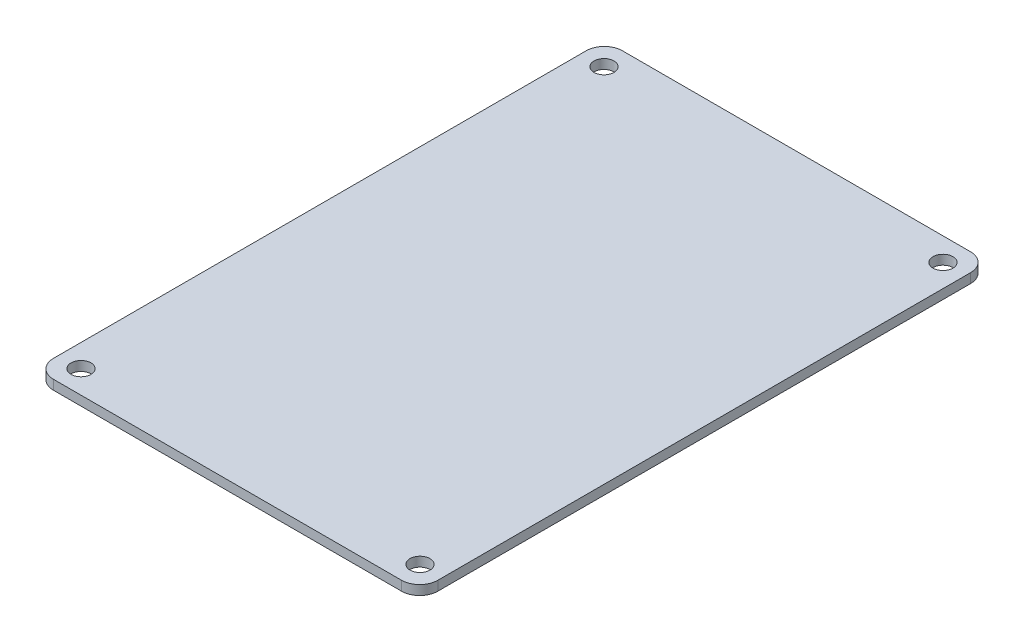
from build123d import *

# Parameters (mm, degrees)
SKETCH1_W           = 63.5
SKETCH1_H           = 94
SKETCH1_R           = 1.65
BOSS_EXTRUDE1_DEPTH = 1.57
FILLET1_R           = 3


with BuildPart() as part:
    # Sketch1 → Boss-Extrude1 (new body)
    with BuildSketch(Plane(origin=(0, 0, 0), x_dir=(1, 0, 0), z_dir=(0, 1, 0))):
        Rectangle(SKETCH1_W, SKETCH1_H)
        with Locations((-28, 43.2)):
            Circle(SKETCH1_R, mode=Mode.SUBTRACT)
        with Locations((28, 43.2)):
            Circle(SKETCH1_R, mode=Mode.SUBTRACT)
        with Locations((28, -43.2)):
            Circle(SKETCH1_R, mode=Mode.SUBTRACT)
        with Locations((-28, -43.2)):
            Circle(SKETCH1_R, mode=Mode.SUBTRACT)
    extrude(amount=BOSS_EXTRUDE1_DEPTH)

    # Fillet1
    fillet1_edges = [part.edges().sort_by_distance(p)[0] for p in [
        (31.75, 0.785, 47),
        (-31.75, 0.785, 47),
        (-31.75, 0.785, -47),
        (31.75, 0.785, -47),
    ]]
    fillet(fillet1_edges, radius=FILLET1_R)


solid = part.part
